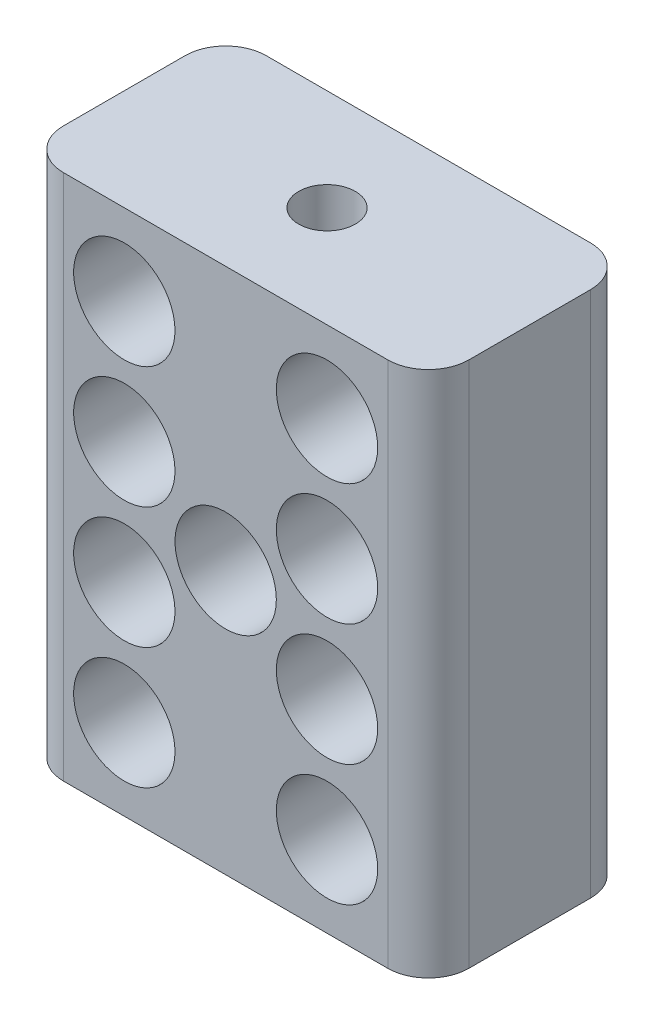
from build123d import *

# Parameters (mm, degrees)
SKETCH2_W           = 10
SKETCH2_H           = 13
SKETCH2_R           = 1.25
BOSS_EXTRUDE1_DEPTH = 5
FILLET1_R           = 1
SKETCH3_R           = 0.7
CUT_EXTRUDE1_DEPTH  = 3


with BuildPart() as part:
    # Sketch2 → Boss-Extrude1 (new body)
    with BuildSketch(Plane.XY):
        Rectangle(SKETCH2_W, SKETCH2_H)
        with Locations((-2.5, 4.5)):
            Circle(SKETCH2_R, mode=Mode.SUBTRACT)
        with Locations((2.5, 4.5)):
            Circle(SKETCH2_R, mode=Mode.SUBTRACT)
        with Locations((2.5, 1.5)):
            Circle(SKETCH2_R, mode=Mode.SUBTRACT)
        with Locations((2.5, -1.5)):
            Circle(SKETCH2_R, mode=Mode.SUBTRACT)
        with Locations((2.5, -4.5)):
            Circle(SKETCH2_R, mode=Mode.SUBTRACT)
        with Locations((-2.5, 1.5)):
            Circle(SKETCH2_R, mode=Mode.SUBTRACT)
        with Locations((-2.5, -1.5)):
            Circle(SKETCH2_R, mode=Mode.SUBTRACT)
        with Locations((-2.5, -4.5)):
            Circle(SKETCH2_R, mode=Mode.SUBTRACT)
        Circle(SKETCH2_R, mode=Mode.SUBTRACT)
    extrude(amount=BOSS_EXTRUDE1_DEPTH)

    # Fillet1
    fillet1_edges = [part.edges().sort_by_distance(p)[0] for p in [
        (-5, 0, 0),
        (5, 0, 0),
        (5, 0, 5),
        (-5, 0, 5),
    ]]
    fillet(fillet1_edges, radius=FILLET1_R)

    # Sketch3 → Cut-Extrude1 (cut)
    with BuildSketch(Plane(origin=(0, 6.5, 0), x_dir=(1, 0, 0), z_dir=(0, 1, 0))):
        with Locations((0, -2.5)):
            Circle(SKETCH3_R)
    cut_extrude1 = extrude(amount=-CUT_EXTRUDE1_DEPTH, mode=Mode.SUBTRACT)

    # Mirror1: Cut-Extrude1 across plane
    add(cut_extrude1.mirror(Plane.ZX), mode=Mode.SUBTRACT)


solid = part.part
